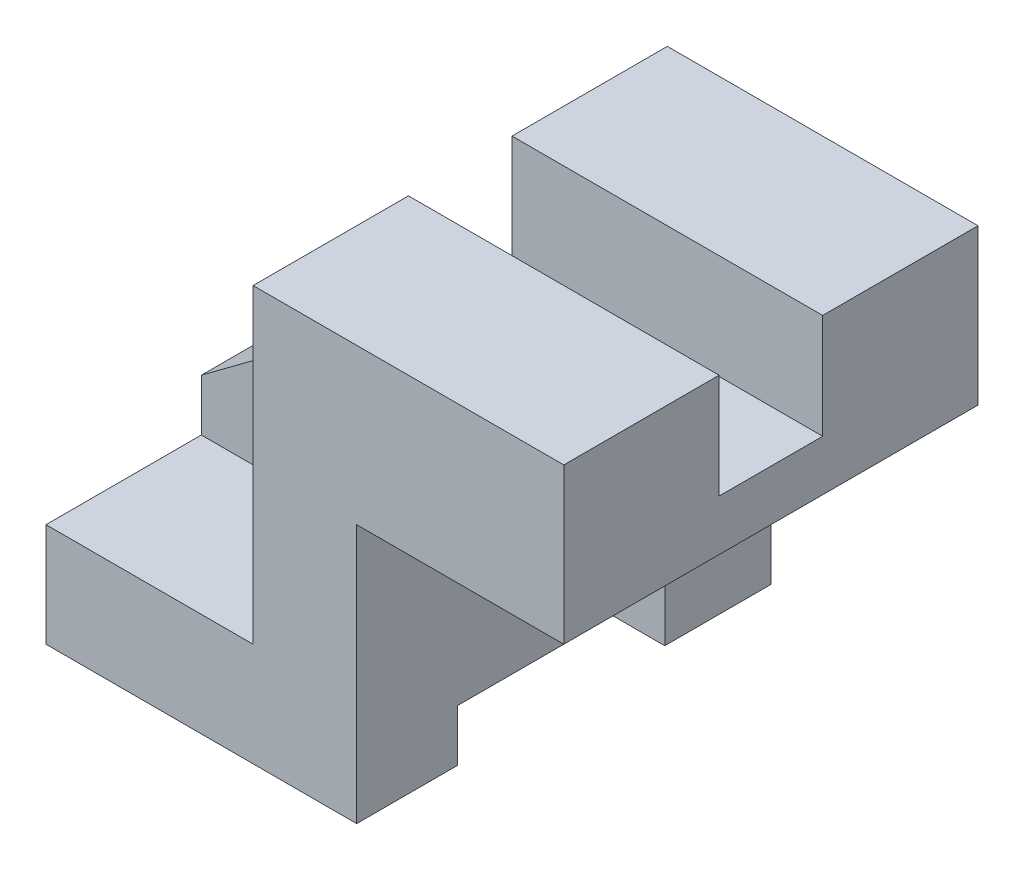
from build123d import *

# Parameters (mm, degrees)
BOSS_EXTRUDE1_DEPTH = 40
CUT_EXTRUDE1_DEPTH  = 30
CUT_EXTRUDE2_DEPTH  = 30
CUT_EXTRUDE3_REACH  = 62
SKETCH4_W           = 20
SKETCH4_H           = 20.212765958
CUT_EXTRUDE4_REACH  = 102
SKETCH5_W           = 40
SKETCH5_H           = 10


with BuildPart() as part:
    # Sketch1 → Boss-Extrude1 (new body, symmetric)
    with BuildSketch(Plane.XY):
        Polygon((-14.731740416, -28.723404255), (-14.731740416, 11.063829787), (-14.731740416, 31.276595745), (45.268259584, 31.276595745), (45.268259584, 1.276595745), (5.268259584, 1.276595745), (5.268259584, -48.723404255), (-54.731740416, -48.723404255), (-54.731740416, -28.723404255), align=None)
        Polygon((-54.731740416, -28.723404255), (-14.731740416, -28.723404255), (-14.731740416, 11.063829787), (-54.731740416, -18.723404255), align=None)
    extrude(amount=BOSS_EXTRUDE1_DEPTH, both=True)

    # Sketch2 → Cut-Extrude1 (cut)
    with BuildSketch(Plane.XY.offset(40)):
        Polygon((-54.731740416, -18.723404255), (-54.731740416, -28.723404255), (-14.731740416, -28.723404255), (-14.731740416, 11.063829787), align=None)
    extrude(amount=-CUT_EXTRUDE1_DEPTH, mode=Mode.SUBTRACT)

    # Sketch3 → Cut-Extrude2 (cut)
    with BuildSketch(Plane(origin=(0, 0, -40), x_dir=(-1, 0, 0), z_dir=(0, 0, -1))):
        Polygon((14.731740416, 11.063829787), (54.731740416, -18.723404255), (54.731740416, -28.723404255), (14.731740416, -28.723404255), align=None)
    extrude(amount=-CUT_EXTRUDE2_DEPTH, mode=Mode.SUBTRACT)

    # Sketch4 → Cut-Extrude3 (cut, up to next)
    with BuildSketch(Plane.ZY.offset(14.731740416), mode=Mode.PRIVATE) as cut_extrude3_sk1:
        with Locations((0, 21.170212766)):
            Rectangle(SKETCH4_W, SKETCH4_H)
    cut_extrude3_tool1 = extrude(cut_extrude3_sk1.sketch, amount=-CUT_EXTRUDE3_REACH, mode=Mode.PRIVATE) & part.part
    add(cut_extrude3_tool1.solids().sort_by_distance((-14.73174, 21.170213, 0))[0], mode=Mode.SUBTRACT)

    # Sketch5 → Cut-Extrude4 (cut, up to next)
    with BuildSketch(Plane.ZY.offset(54.731740416), mode=Mode.PRIVATE) as cut_extrude4_sk1:
        with Locations((0.497624841, -43.723404255)):
            Rectangle(SKETCH5_W, SKETCH5_H)
    cut_extrude4_tool1 = extrude(cut_extrude4_sk1.sketch, amount=-CUT_EXTRUDE4_REACH, mode=Mode.PRIVATE) & part.part
    add(cut_extrude4_tool1.solids().sort_by_distance((-54.73174, -43.723404, 0.497625))[0], mode=Mode.SUBTRACT)


solid = part.part
